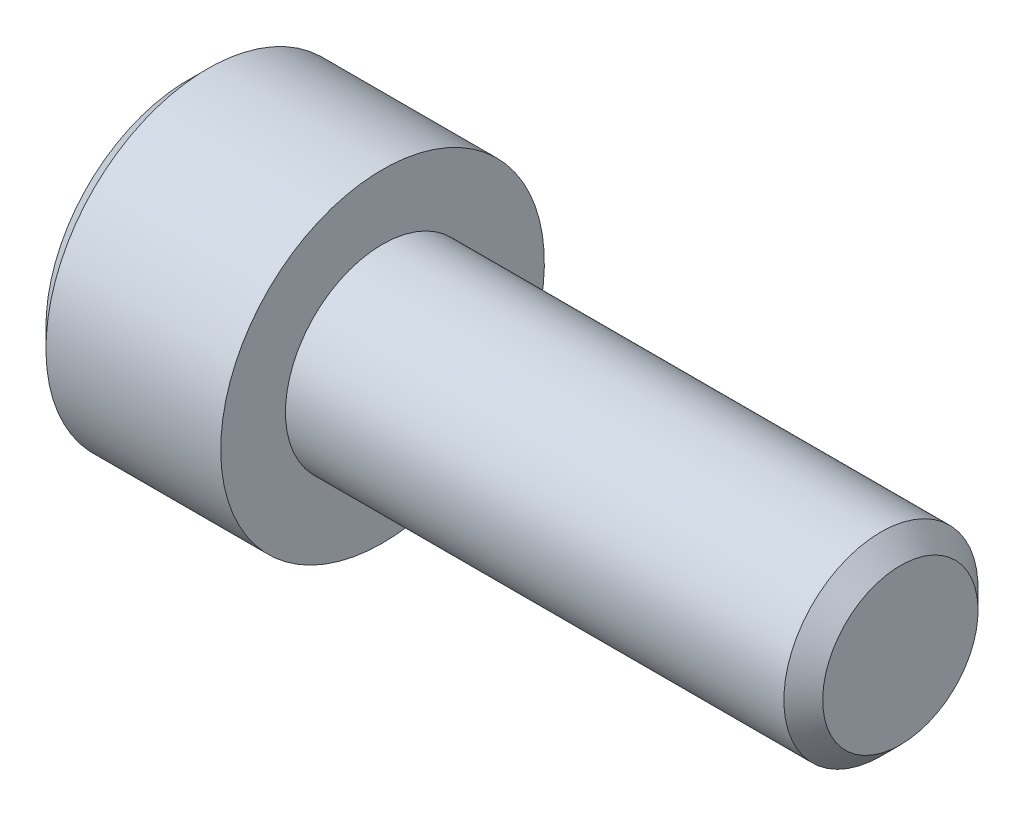
from build123d import *

# Parameters (mm, degrees)
CHAMFER1_SIZE      = 0.6
CUT_EXTRUDE1_DEPTH = 3


with BuildPart() as part:
    # Sketch1 → Revolve1 (revolve)
    with BuildSketch(Plane.XY):
        Polygon((-6, 0), (-6, 4.4), (-5.4, 5), (0, 5), (0, 3), (16, 3), (16, 0), align=None)
    revolve(axis=Axis((16, 0, 0), (-1, 0, 0)))

    # Chamfer1
    chamfer1_edges = [part.edges().sort_by_distance(p)[0] for p in [
        (16, -3, 0),
    ]]
    chamfer(chamfer1_edges, length=CHAMFER1_SIZE)

    # Sketch2 → Cut-Revolve1 (revolve, cut)
    with BuildSketch(Plane.XY):
        Polygon((-6, 0), (-6, 2.5), (-3, 2.5), (-2.330127019, 0), align=None)
    revolve(axis=Axis((-2.330127019, 0, 0), (-1, 0, 0)), mode=Mode.SUBTRACT)

    # Sketch3 → Cut-Extrude1 (cut)
    with BuildSketch(Plane(origin=(-6, 0, 0), x_dir=(0, 0, -1), z_dir=(1, 0, 0))):
        Polygon((-2.5, 1.443375673), (-2.5, -1.443375673), (0, -2.886751346), (2.5, -1.443375673), (2.5, 1.443375673), (0, 2.886751346), align=None)
    extrude(amount=CUT_EXTRUDE1_DEPTH, mode=Mode.SUBTRACT)


solid = part.part
